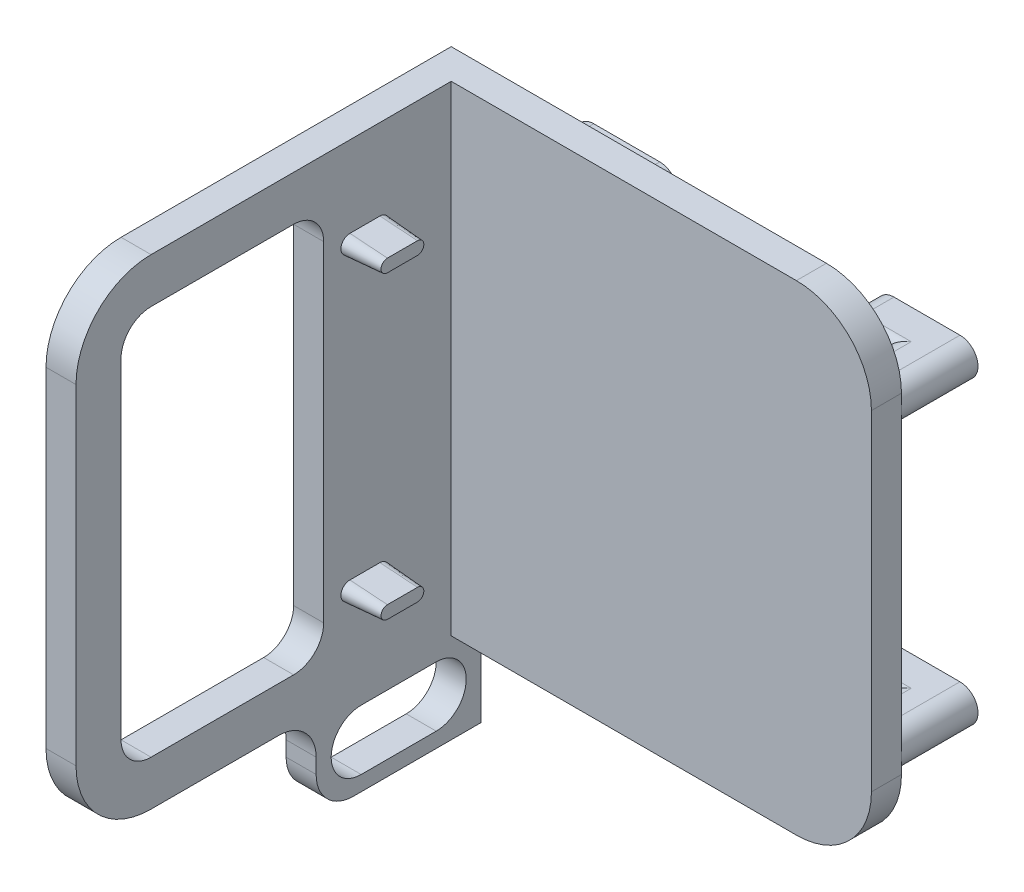
from build123d import *

# Parameters (mm, degrees)
SKETCH_1_W                = 60
SKETCH_1_H                = 4
EXTRUDE_1_DEPTH           = 64
SKETCH_2_W                = 4
SKETCH_2_H                = 64
EXTRUDE_2_DEPTH           = 50
FILLET_1_R                = 10
CUT_EXTRUDE_1_REACH       = 92.324
SKETCH_4_W                = 11
SKETCH_4_H                = 52
EXTRUDE_3_DEPTH           = 4
EXTRUDE_4_DEPTH           = 5
EXTRUDE_4_DRAFT           = 4
EXTRUDE_4_PROFILE_2_DEPTH = 5
EXTRUDE_4_PROFILE_2_DRAFT = 4
FILLET_2_R                = 4
EXTRUDE_5_DEPTH           = 5.2
EXTRUDE_6_DEPTH           = 5
FILLET_3_R                = 1
SKETCH_8_W                = 4
SKETCH_8_H                = 22
EXTRUDE_7_DEPTH           = 12
FILLET_4_R                = 5
CUT_EXTRUDE_2_REACH       = 96.252


with BuildPart() as part:
    # 草图1 → 凸台-拉伸1 (new body)
    with BuildSketch(Plane(origin=(0, 0, 0), x_dir=(1, 0, 0), z_dir=(0, 1, 0))):
        with Locations((-88.556547212, 28.436915988)):
            Rectangle(SKETCH_1_W, SKETCH_1_H)
    extrude(amount=EXTRUDE_1_DEPTH)

    # 草图2 → 凸台-拉伸2 (add)
    with BuildSketch(Plane.XY.offset(-26.436915988)):
        with Locations((-116.556547212, 32)):
            Rectangle(SKETCH_2_W, SKETCH_2_H)
    extrude(amount=EXTRUDE_2_DEPTH)

    # 圆角1
    fillet_1_edges = [part.edges().sort_by_distance(p)[0] for p in [
        (-58.556547212, 64, -28.436915988),
        (-116.556547212, 0, 23.563084012),
        (-116.556547212, 64, 23.563084012),
        (-58.556547212, 0, -28.436915988),
    ]]
    fillet(fillet_1_edges, radius=FILLET_1_R)

    # 草图3 → 切除-拉伸1 (cut, up to next)
    with BuildSketch(Plane(origin=(-114.556547212, 0, 0), x_dir=(0, 0, -1), z_dir=(1, 0, 0)), mode=Mode.PRIVATE) as cut_extrude_1_sk1:
        with BuildLine():
            Line((-17.563084012, 54), (-17.563084012, 10))
            ThreePointArc((-17.563084012, 10), (-16.391511137, 7.171572875), (-13.563084012, 6))
            Line((-13.563084012, 6), (20.436915988, 6))
            Line((20.436915988, 6), (20.436915988, 58))
            Line((20.436915988, 58), (-13.563084012, 58))
            ThreePointArc((-13.563084012, 58), (-16.391511137, 56.828427125), (-17.563084012, 54))
        make_face()
    cut_extrude_1_tool1 = extrude(cut_extrude_1_sk1.sketch, amount=-CUT_EXTRUDE_1_REACH, mode=Mode.PRIVATE) & part.part
    add(cut_extrude_1_tool1.solids().sort_by_distance((-114.556547, 32, -1.500062))[0], mode=Mode.SUBTRACT)


with BuildPart() as body_2:
    # 草图4 → 凸台-拉伸3 (new body)
    with BuildSketch(Plane.ZY.offset(118.556547212)):
        with Locations((-14.936915988, 32)):
            Rectangle(SKETCH_4_W, SKETCH_4_H)
    extrude(amount=-EXTRUDE_3_DEPTH)


with BuildPart() as extrude_4_tool:
    # 草图5 → 凸台-拉伸4 (with draft: the straight prism first)
    with BuildSketch(Plane(origin=(-114.556547212, 0, 0), x_dir=(0, 0, -1), z_dir=(1, 0, 0))):
        with BuildLine():
            ThreePointArc((12.936915988, 53.2), (11.736915988, 52), (12.936915988, 50.8))
            Line((12.936915988, 50.8), (16.936915988, 50.8))
            ThreePointArc((16.936915988, 50.8), (18.136915988, 52), (16.936915988, 53.2))
            Line((16.936915988, 53.2), (12.936915988, 53.2))
        make_face()
    extrude(amount=EXTRUDE_4_DEPTH)
    # 凸台-拉伸4: the draft: its side faces are tilted about the plane it starts from
    extrude_4_sides = [extrude_4_tool.faces().sort_by_distance(p)[0] for p in [
        (-112.056547212, 52, -18.136915988),
        (-112.056547212, 53.2, -14.936915988),
        (-112.056547212, 52, -11.736915988),
        (-112.056547212, 50.8, -14.936915988),
    ]]
    draft(extrude_4_sides, Plane(origin=(-114.556547212, 0, 0), x_dir=(0, 0, -1), z_dir=(1, 0, 0)), EXTRUDE_4_DRAFT)


with BuildPart() as part_1:
    add(part.part)

    # 凸台-拉伸4: add extrude_4_tool
    add(extrude_4_tool.part)

    add(body_2.part)  # 凸台-拉伸4 merges body 2


with BuildPart() as extrude_4_profile_2_tool:
    # 草图5 → 凸台-拉伸4 profile 2 (with draft: the straight prism first)
    with BuildSketch(Plane(origin=(-114.556547212, 0, 0), x_dir=(0, 0, -1), z_dir=(1, 0, 0))):
        with BuildLine():
            ThreePointArc((12.936915988, 13.2), (11.736915988, 12), (12.936915988, 10.8))
            Line((12.936915988, 10.8), (16.936915988, 10.8))
            ThreePointArc((16.936915988, 10.8), (18.136915988, 12), (16.936915988, 13.2))
            Line((16.936915988, 13.2), (12.936915988, 13.2))
        make_face()
    extrude(amount=EXTRUDE_4_PROFILE_2_DEPTH)
    # 凸台-拉伸4 profile 2: the draft: its side faces are tilted about the plane it starts from
    extrude_4_profile_2_sides = [extrude_4_profile_2_tool.faces().sort_by_distance(p)[0] for p in [
        (-112.056547212, 12, -11.736915988),
        (-112.056547212, 10.8, -14.936915988),
        (-112.056547212, 12, -18.136915988),
        (-112.056547212, 13.2, -14.936915988),
    ]]
    draft(extrude_4_profile_2_sides, Plane(origin=(-114.556547212, 0, 0), x_dir=(0, 0, -1), z_dir=(1, 0, 0)), EXTRUDE_4_PROFILE_2_DRAFT)


with BuildPart() as part_2:
    add(part_1.part)

    # 凸台-拉伸4 profile 2: add extrude_4_profile_2_tool
    add(extrude_4_profile_2_tool.part)

    # 圆角2
    fillet_2_edges = [part_2.edges().sort_by_distance(p)[0] for p in [
        (-116.556547212, 58, -9.436915988),
        (-116.556547212, 6, -9.436915988),
    ]]
    fillet(fillet_2_edges, radius=FILLET_2_R)

    # 草图6 → 凸台-拉伸5 (add)
    with BuildSketch(Plane(origin=(0, 0, -30.436915988), x_dir=(-1, 0, 0), z_dir=(0, 0, -1))):
        with BuildLine():
            Line((60.956547212, 54.4), (63.456547212, 54.4))
            ThreePointArc((63.456547212, 54.4), (65.856547212, 52), (63.456547212, 49.6))
            Line((63.456547212, 49.6), (60.956547212, 49.6))
            ThreePointArc((60.956547212, 49.6), (58.556547212, 52), (60.956547212, 54.4))
        make_face()
        with BuildLine():
            Line((100.956547212, 54.4), (103.456547212, 54.4))
            ThreePointArc((103.456547212, 54.4), (105.856547212, 52), (103.456547212, 49.6))
            Line((103.456547212, 49.6), (100.956547212, 49.6))
            ThreePointArc((100.956547212, 49.6), (98.556547212, 52), (100.956547212, 54.4))
        make_face()
        with BuildLine():
            Line((100.956547212, 14.4), (103.456547212, 14.4))
            ThreePointArc((103.456547212, 14.4), (105.856547212, 12), (103.456547212, 9.6))
            Line((103.456547212, 9.6), (100.956547212, 9.6))
            ThreePointArc((100.956547212, 9.6), (98.556547212, 12), (100.956547212, 14.4))
        make_face()
        with BuildLine():
            Line((60.956547212, 14.4), (63.456547212, 14.4))
            ThreePointArc((63.456547212, 14.4), (65.856547212, 12), (63.456547212, 9.6))
            Line((63.456547212, 9.6), (60.956547212, 9.6))
            ThreePointArc((60.956547212, 9.6), (58.556547212, 12), (60.956547212, 14.4))
        make_face()
    extrude(amount=EXTRUDE_5_DEPTH)

    # 草图7 → 凸台-拉伸6 (add)
    with BuildSketch(Plane(origin=(0, 0, -35.636915988), x_dir=(-1, 0, 0), z_dir=(0, 0, -1))):
        with BuildLine():
            Line((60.956547212, 54.4), (69.756547212, 54.4))
            ThreePointArc((69.756547212, 54.4), (72.156547212, 52), (69.756547212, 49.6))
            Line((69.756547212, 49.6), (60.956547212, 49.6))
            ThreePointArc((60.956547212, 49.6), (58.556547212, 52), (60.956547212, 54.4))
        make_face()
        with BuildLine():
            Line((100.956547212, 54.4), (109.756547212, 54.4))
            ThreePointArc((109.756547212, 54.4), (112.156547212, 52), (109.756547212, 49.6))
            Line((109.756547212, 49.6), (100.956547212, 49.6))
            ThreePointArc((100.956547212, 49.6), (98.556547212, 52), (100.956547212, 54.4))
        make_face()
        with BuildLine():
            Line((100.956547212, 14.4), (109.756547212, 14.4))
            ThreePointArc((109.756547212, 14.4), (112.156547212, 12), (109.756547212, 9.6))
            Line((109.756547212, 9.6), (100.956547212, 9.6))
            ThreePointArc((100.956547212, 9.6), (98.556547212, 12), (100.956547212, 14.4))
        make_face()
        with BuildLine():
            Line((60.956547212, 14.4), (69.756547212, 14.4))
            ThreePointArc((69.756547212, 14.4), (72.156547212, 12), (69.756547212, 9.6))
            Line((69.756547212, 9.6), (60.956547212, 9.6))
            ThreePointArc((60.956547212, 9.6), (58.556547212, 12), (60.956547212, 14.4))
        make_face()
    extrude(amount=EXTRUDE_6_DEPTH)

    # 圆角3
    fillet_3_edges = [part_2.edges().sort_by_distance(p)[0] for p in [
        (-66.606547212, 49.6, -35.636915988),
        (-72.156547212, 52, -35.636915988),
        (-66.606547212, 54.4, -35.636915988),
        (-106.606547212, 49.6, -35.636915988),
        (-112.156547212, 52, -35.636915988),
        (-106.606547212, 54.4, -35.636915988),
        (-106.606547212, 9.6, -35.636915988),
        (-112.156547212, 12, -35.636915988),
        (-106.606547212, 14.4, -35.636915988),
        (-66.606547212, 9.6, -35.636915988),
        (-72.156547212, 12, -35.636915988),
        (-66.606547212, 14.4, -35.636915988),
    ]]
    fillet(fillet_3_edges, radius=FILLET_3_R)

    # 草图8 → 凸台-拉伸7 (add)
    with BuildSketch(Plane.XZ):
        with Locations((-116.556547212, -19.436915988)):
            Rectangle(SKETCH_8_W, SKETCH_8_H)
    extrude(amount=EXTRUDE_7_DEPTH)

    # 圆角4
    fillet_4_edges = [part_2.edges().sort_by_distance(p)[0] for p in [
        (-116.556547212, 0, -8.436915988),
        (-116.556547212, -12, -8.436915988),
    ]]
    fillet(fillet_4_edges, radius=FILLET_4_R)

    # 草图9 → 切除-拉伸2 (cut, up to next)
    with BuildSketch(Plane(origin=(-114.556547212, 0, 0), x_dir=(0, 0, -1), z_dir=(1, 0, 0)), mode=Mode.PRIVATE) as cut_extrude_2_sk1:
        with BuildLine():
            Line((14.436915988, -2), (24.436915988, -2))
            ThreePointArc((24.436915988, -2), (28.436915988, -6), (24.436915988, -10))
            Line((24.436915988, -10), (14.436915988, -10))
            ThreePointArc((14.436915988, -10), (10.436915988, -6), (14.436915988, -2))
        make_face()
    cut_extrude_2_tool1 = extrude(cut_extrude_2_sk1.sketch, amount=-CUT_EXTRUDE_2_REACH, mode=Mode.PRIVATE) & part_2.part
    add(cut_extrude_2_tool1.solids().sort_by_distance((-114.556547, -6, -19.436916))[0], mode=Mode.SUBTRACT)


solid = part_2.part
